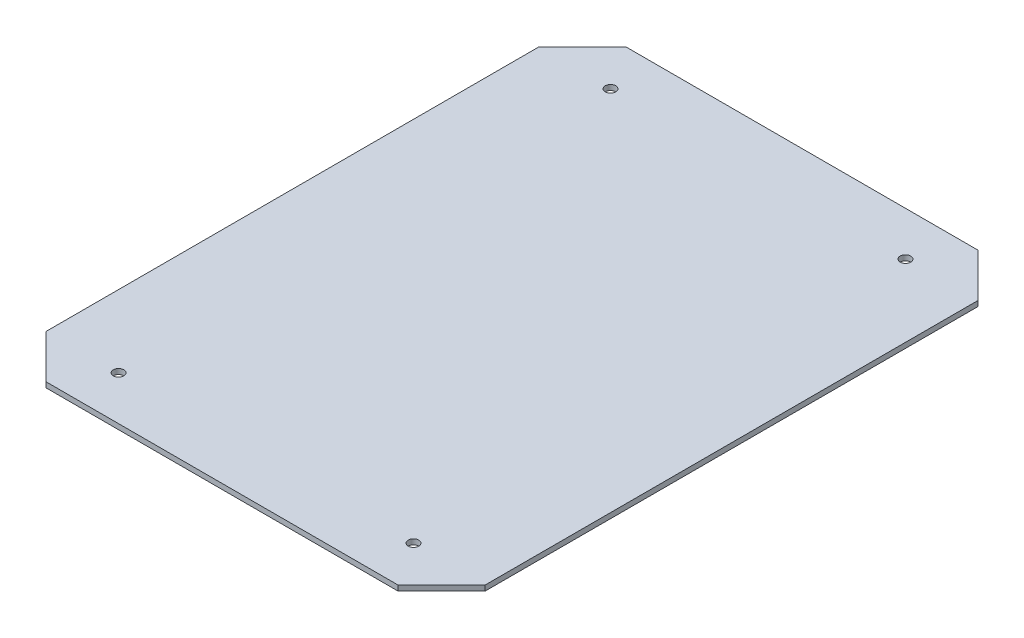
from build123d import *

# Parameters (mm, degrees)
BOSS_EXTRU_1_DEPTH      = 3
ESQUISSE2_R             = 3
ENL_V_MAT_EXTRU_1_DEPTH = 4


with BuildPart() as part:
    # Esquisse1 → Boss.-Extru.1 (new body)
    with BuildSketch(Plane(origin=(0, 0, 0), x_dir=(1, 0, 0), z_dir=(0, 1, 0))):
        Polygon((100, -164.748737342), (-100, -164.748737342), (-124.748737342, -140), (-124.748737342, 140), (-100, 164.748737342), (100, 164.748737342), (124.748737342, 140), (124.748737342, -140), align=None)
    extrude(amount=BOSS_EXTRU_1_DEPTH)

    # Esquisse2 → Enlèv. mat.-Extru.1 (cut, through all)
    with BuildSketch(Plane(origin=(0, 3, 0), x_dir=(1, 0, 0), z_dir=(0, 1, 0))):
        with Locations((-83.786796564, 139.748737342)):
            Circle(ESQUISSE2_R)
        with Locations((83.786796564, 139.748737342)):
            Circle(ESQUISSE2_R)
        with Locations((83.786796564, -139.748737342)):
            Circle(ESQUISSE2_R)
        with Locations((-83.786796564, -139.748737342)):
            Circle(ESQUISSE2_R)
    extrude(amount=-ENL_V_MAT_EXTRU_1_DEPTH, mode=Mode.SUBTRACT)


solid = part.part
